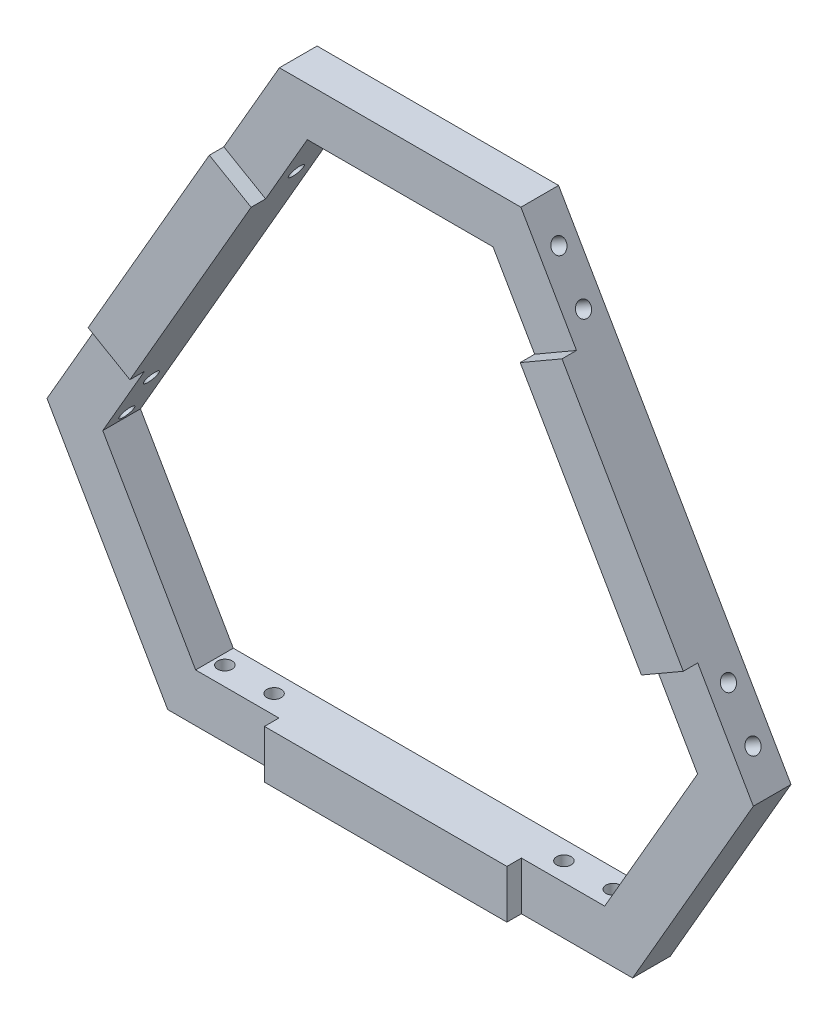
from build123d import *

# Parameters (mm, degrees)
EXTRUDE_1_DEPTH     = 7.8
SKETCH_3_R          = 1.5
CUT_EXTRUDE_1_DEPTH = 12
SKETCH_9_R          = 1.5
CUT_EXTRUDE_2_DEPTH = 12
SKETCH_10_R         = 1.5
CUT_EXTRUDE_3_DEPTH = 12
CUT_EXTRUDE_4_DEPTH = 8.8
SKETCH_14_W         = 50.2
SKETCH_14_H         = 10
EXTRUDE_2_DEPTH     = 3


with BuildPart() as part:
    # 草圖1 → 填料-伸長1 (new body)
    with BuildSketch(Plane.XY):
        Polygon((-25, 70), (25, 70), (73.121778265, -13.349364905), (48.121778265, -56.650635095), (-48.121778265, -56.650635095), (-73.121778265, -13.349364905), align=None)
    extrude(amount=EXTRUDE_1_DEPTH)

    # 草圖3 → 除料-伸長1 (cut)
    with BuildSketch(Plane(origin=(-49.060889132, 28.325317547, 0), x_dir=(0, 0, 1), z_dir=(-0.866025404, 0.5, 0))):
        with Locations((3.9, 40.2)):
            Circle(SKETCH_3_R)
        with Locations((3.9, 30)):
            Circle(SKETCH_3_R)
        with Locations((3.9, -30)):
            Circle(SKETCH_3_R)
        with Locations((3.9, -40.2)):
            Circle(SKETCH_3_R)
    extrude(amount=-CUT_EXTRUDE_1_DEPTH, mode=Mode.SUBTRACT)

    # 草圖9 → 除料-伸長2 (cut)
    with BuildSketch(Plane.XZ.offset(56.650635095)):
        with Locations((-30, 3.9)):
            Circle(SKETCH_9_R)
        with Locations((-40.2, 3.9)):
            Circle(SKETCH_9_R)
        with Locations((40.2, 3.9)):
            Circle(SKETCH_9_R)
        with Locations((30, 3.9)):
            Circle(SKETCH_9_R)
    extrude(amount=-CUT_EXTRUDE_2_DEPTH, mode=Mode.SUBTRACT)

    # 草圖10 → 除料-伸長3 (cut)
    with BuildSketch(Plane(origin=(49.060889132, 28.325317547, 0), x_dir=(0, 0, -1), z_dir=(0.866025404, 0.5, 0))):
        with Locations((-3.9, 40.2)):
            Circle(SKETCH_10_R)
        with Locations((-3.9, 30)):
            Circle(SKETCH_10_R)
        with Locations((-3.9, -30)):
            Circle(SKETCH_10_R)
        with Locations((-3.9, -40.2)):
            Circle(SKETCH_10_R)
    extrude(amount=-CUT_EXTRUDE_3_DEPTH, mode=Mode.SUBTRACT)

    # 草圖13 → 除料-伸長4 (cut, through all)
    with BuildSketch(Plane.XY.offset(7.8)):
        Polygon((-61.574772881, -13.349364905), (-19.226497308, 60), (19.226497308, 60), (61.574772881, -13.349364905), (42.348275573, -46.650635095), (-42.348275573, -46.650635095), align=None)
    extrude(amount=-CUT_EXTRUDE_4_DEPTH, mode=Mode.SUBTRACT)

    # 草圖14 → 填料-伸長2 (add)
    with BuildSketch(Plane.XY.offset(7.8)):
        Polygon((-27.850635095, 45.062555182), (-36.510889132, 50.062555182), (-61.610889132, 6.588079912), (-52.950635095, 1.588079912), align=None)
        Polygon((36.510889132, 50.062555182), (27.850635095, 45.062555182), (52.950635095, 1.588079912), (61.610889132, 6.588079912), align=None)
        with Locations((0, -51.650635095)):
            Rectangle(SKETCH_14_W, SKETCH_14_H)
    extrude(amount=EXTRUDE_2_DEPTH)


solid = part.part
